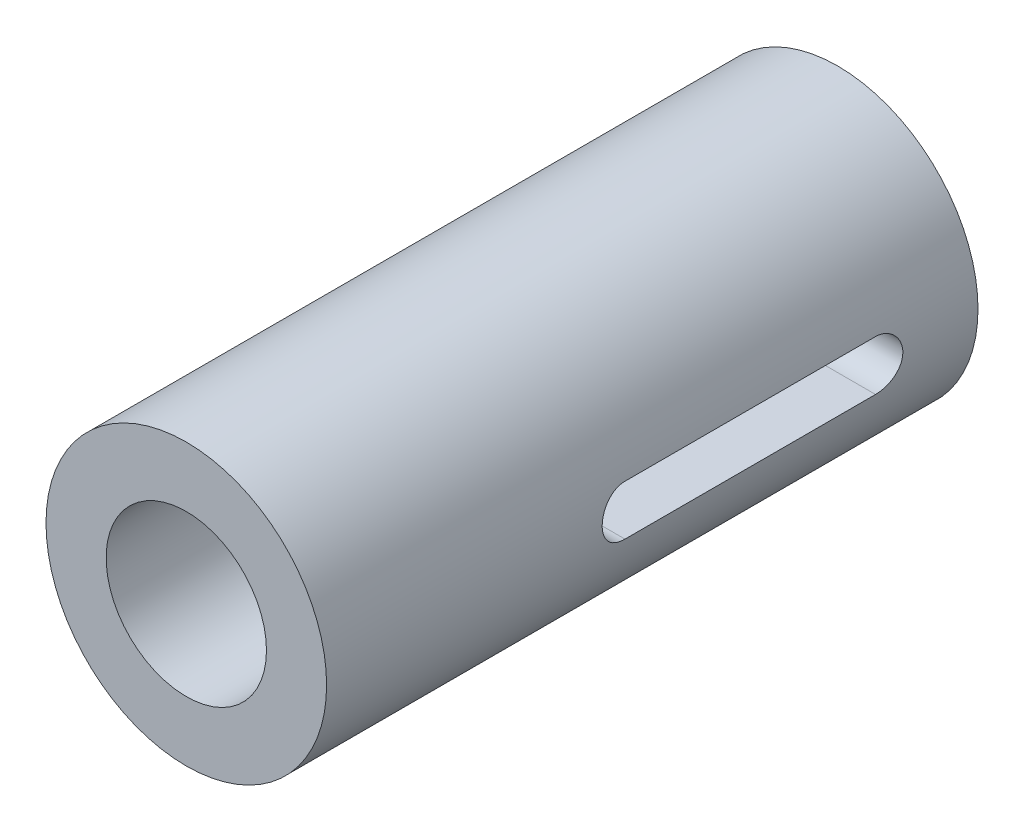
from build123d import *

# Parameters (mm, degrees)
SCHIZZO1_R                                    = 14
SCHIZZO1_R_2                                  = 8
ESTRUSIONE_ESTRUSIONE1_DEPTH                  = 20
ESTRUSIONE_ESTRUSIONE2_REACH                  = 30.142
ESTRUSIONE_ESTRUSIONE2_END_RADIUS             = 14
SCHIZZO2_W                                    = 45
SCHIZZO2_H                                    = 28
ESTRUSIONE_ESTRUSIONE2_DIRECTION_2_REACH      = 30.142
ESTRUSIONE_ESTRUSIONE2_DIRECTION_2_END_RADIUS = 14


with BuildPart() as part:
    # Schizzo1 → Estrusione-Estrusione1 (new body)
    with BuildSketch(Plane.XY):
        Circle(SCHIZZO1_R)
        Circle(SCHIZZO1_R_2, mode=Mode.SUBTRACT)
    extrude(amount=ESTRUSIONE_ESTRUSIONE1_DEPTH)

    # Estrusione-Estrusione2: up to this cylinder (the profile starts inside it)
    estrusione_estrusione2_end = Plane(origin=(0, 0, -22.5), z_dir=(0, 0, -1)) * Cylinder(ESTRUSIONE_ESTRUSIONE2_END_RADIUS, 89.284, mode=Mode.PRIVATE)
    # Schizzo2 → Estrusione-Estrusione2 (add, up to the surface)
    with BuildSketch(Plane(origin=(0, 0, 0), x_dir=(0, 0, -1), z_dir=(1, 0, 0)), mode=Mode.PRIVATE) as estrusione_estrusione2_sk1:
        with Locations((22.5, 0)):
            Rectangle(SCHIZZO2_W, SCHIZZO2_H)
        with BuildLine():
            Line((35, -2.5), (10, -2.5))
            ThreePointArc((10, -2.5), (7.5, 0), (10, 2.5))
            Line((10, 2.5), (35, 2.5))
            ThreePointArc((35, 2.5), (37.5, 0), (35, -2.5))
        make_face(mode=Mode.SUBTRACT)
    estrusione_estrusione2_tool1 = extrude(estrusione_estrusione2_sk1.sketch, amount=ESTRUSIONE_ESTRUSIONE2_REACH, mode=Mode.PRIVATE) & estrusione_estrusione2_end
    add(estrusione_estrusione2_tool1.solids().sort_by_distance((0, -13.47, -22.5))[0])

    # Estrusione-Estrusione2 direction 2: up to this cylinder (the profile starts inside it)
    estrusione_estrusione2_direction_2_end = Plane(origin=(0, 0, -22.5), z_dir=(0, 0, -1)) * Cylinder(ESTRUSIONE_ESTRUSIONE2_DIRECTION_2_END_RADIUS, 89.284, mode=Mode.PRIVATE)
    # Schizzo2 → Estrusione-Estrusione2 direction 2 (add, up to the surface)
    with BuildSketch(Plane(origin=(0, 0, 0), x_dir=(0, 0, -1), z_dir=(1, 0, 0)), mode=Mode.PRIVATE) as estrusione_estrusione2_direction_2_sk1:
        with Locations((22.5, 0)):
            Rectangle(SCHIZZO2_W, SCHIZZO2_H)
        with BuildLine():
            Line((35, -2.5), (10, -2.5))
            ThreePointArc((10, -2.5), (7.5, 0), (10, 2.5))
            Line((10, 2.5), (35, 2.5))
            ThreePointArc((35, 2.5), (37.5, 0), (35, -2.5))
        make_face(mode=Mode.SUBTRACT)
    estrusione_estrusione2_direction_2_tool1 = extrude(estrusione_estrusione2_direction_2_sk1.sketch, amount=-ESTRUSIONE_ESTRUSIONE2_DIRECTION_2_REACH, mode=Mode.PRIVATE) & estrusione_estrusione2_direction_2_end
    add(estrusione_estrusione2_direction_2_tool1.solids().sort_by_distance((0, -13.47, -22.5))[0])


solid = part.part
